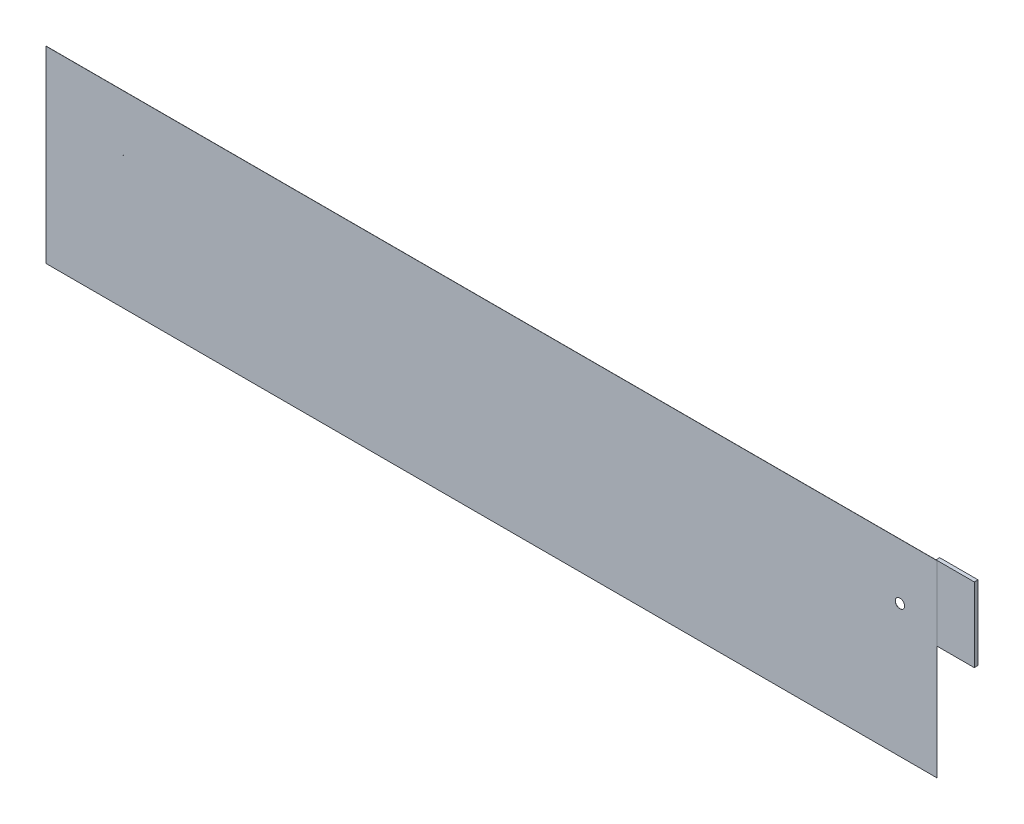
from build123d import *

# Parameters (mm, degrees)
SKETCH1_W           = 609.6
SKETCH1_H           = 128.778
SKETCH1_R           = 0.174798991
SKETCH1_R_2         = 3.175
BOSS_EXTRUDE1_DEPTH = 0.0999998
SKETCH2_W           = 25.4
SKETCH2_H           = 50.8
SKETCH2_W_2         = 0.79375
BOSS_EXTRUDE2_DEPTH = 2.54


with BuildPart() as part:
    # Sketch1 → Boss-Extrude1 (new body)
    with BuildSketch(Plane.XY):
        with Locations((304.8, 64.389)):
            Rectangle(SKETCH1_W, SKETCH1_H)
        with Locations((52.974692136, 90.678)):
            Circle(SKETCH1_R, mode=Mode.SUBTRACT)
        with Locations((584.2, 90.678)):
            Circle(SKETCH1_R_2, mode=Mode.SUBTRACT)
    extrude(amount=BOSS_EXTRUDE1_DEPTH)

    # Sketch2 → Boss-Extrude2 (add)
    with BuildSketch(Plane(origin=(0, 0, 0), x_dir=(-1, 0, 0), z_dir=(0, 0, -1))):
        with Locations((-622.3, 103.378)):
            Rectangle(SKETCH2_W, SKETCH2_H)
        with Locations((-609.203125, 103.378)):
            Rectangle(SKETCH2_W_2, SKETCH2_H)
    extrude(amount=BOSS_EXTRUDE2_DEPTH)


solid = part.part
